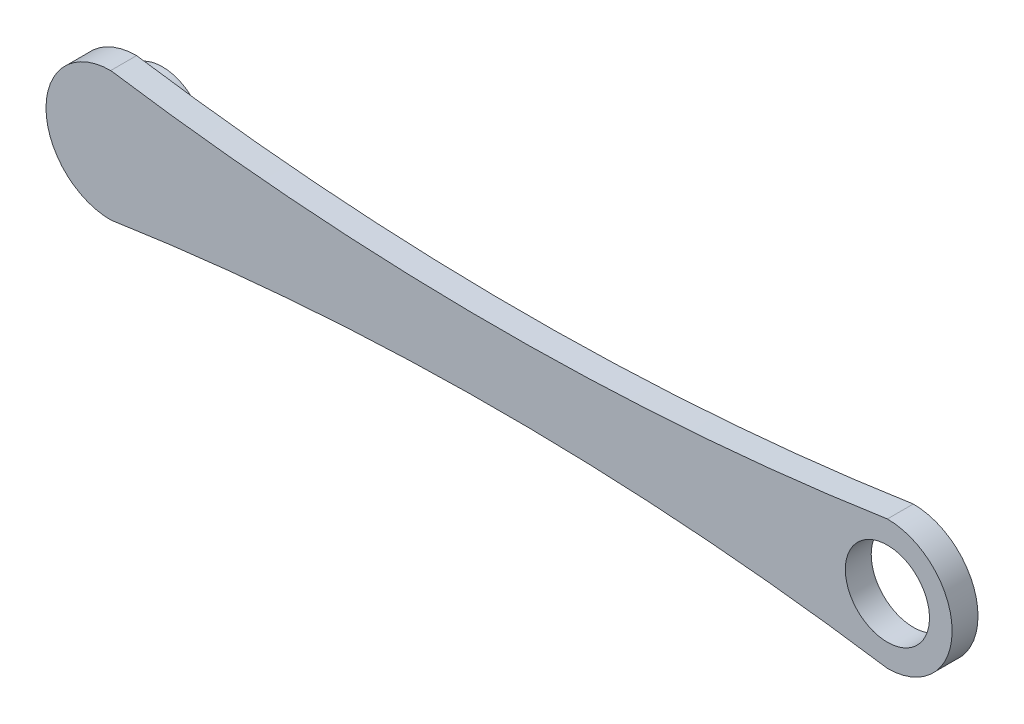
from build123d import *

# Parameters (mm, degrees)
BOSS_EXTRUDE1_DEPTH = 10
SKETCH2_R           = 16.25
BOSS_EXTRUDE2_DEPTH = 10
SKETCH3_R           = 16.25
CUT_EXTRUDE4_DEPTH  = 10


with BuildPart() as part:
    # Sketch1 → Boss-Extrude1 (new body)
    with BuildSketch(Plane.XY):
        with BuildLine():
            ThreePointArc((-150, 25), (-175, 0), (-150, -25))
            ThreePointArc((-150, -25), (0, -13.685996664), (150, -25))
            ThreePointArc((150, -25), (175, 0), (150, 25))
            ThreePointArc((150, 25), (0, 13.685996664), (-150, 25))
        make_face()
    extrude(amount=BOSS_EXTRUDE1_DEPTH)

    # Sketch2 → Boss-Extrude2 (add)
    with BuildSketch(Plane(origin=(0, 0, 0), x_dir=(1, 0, 0), z_dir=(0, 0, -1))):
        with Locations((-150, 0)):
            Circle(SKETCH2_R)
    extrude(amount=BOSS_EXTRUDE2_DEPTH)

    # Sketch3 → Cut-Extrude4 (cut)
    with BuildSketch(Plane.XY.offset(10)):
        with Locations((150, 0)):
            Circle(SKETCH3_R)
    extrude(amount=-CUT_EXTRUDE4_DEPTH, mode=Mode.SUBTRACT)


solid = part.part
